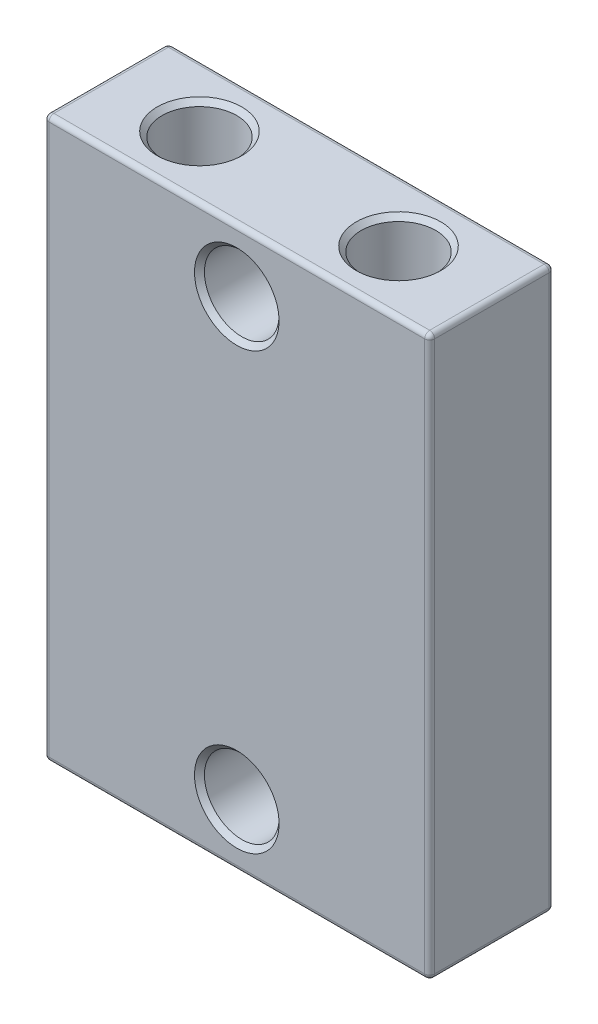
from build123d import *

# Parameters (mm, degrees)
SKETCH1_W           = 15.5
SKETCH1_H           = 22.5
BOSS_EXTRUDE1_DEPTH = 5
SKETCH2_R           = 1.5
CUT_EXTRUDE1_DEPTH  = 6
SKETCH3_R           = 1.5
CUT_EXTRUDE2_DEPTH  = 8
FILLET1_R           = 0.2
CHAMFER1_SIZE       = 0.2


with BuildPart() as part:
    # Sketch1 → Boss-Extrude1 (new body)
    with BuildSketch(Plane.XY):
        Rectangle(SKETCH1_W, SKETCH1_H)
    extrude(amount=BOSS_EXTRUDE1_DEPTH)

    # Sketch2 → Cut-Extrude1 (cut, through all)
    with BuildSketch(Plane.XY.offset(5)):
        with Locations((0, 8.75)):
            Circle(SKETCH2_R)
        with Locations((0, -8.75)):
            Circle(SKETCH2_R)
    extrude(amount=-CUT_EXTRUDE1_DEPTH, mode=Mode.SUBTRACT)

    # Sketch3 → Cut-Extrude2 (cut)
    with BuildSketch(Plane(origin=(0, 11.25, 0), x_dir=(1, 0, 0), z_dir=(0, 1, 0))):
        with Locations((-4, -2.5)):
            Circle(SKETCH3_R)
        with Locations((4, -2.5)):
            Circle(SKETCH3_R)
    extrude(amount=-CUT_EXTRUDE2_DEPTH, mode=Mode.SUBTRACT)

    # Fillet1
    fillet1_edges = [part.edges().sort_by_distance(p)[0] for p in [
        (-7.75, 0, 5),
        (0, -11.25, 5),
        (7.75, 0, 5),
        (0, -11.25, 0),
        (-7.75, 0, 0),
        (0, 11.25, 0),
        (7.75, 0, 0),
        (0, 11.25, 5),
        (7.75, -11.25, 2.5),
        (-7.75, -11.25, 2.5),
        (-7.75, 11.25, 2.5),
        (7.75, 11.25, 2.5),
    ]]
    fillet(fillet1_edges, radius=FILLET1_R)

    # Chamfer1
    chamfer1_edges = [part.edges().sort_by_distance(p)[0] for p in [
        (-1.5, 8.75, 0),
        (-1.5, 8.75, 5),
        (-1.5, -8.75, 5),
        (-5.5, 11.25, 2.5),
        (2.5, 11.25, 2.5),
    ]]
    chamfer(chamfer1_edges, length=CHAMFER1_SIZE)


solid = part.part
